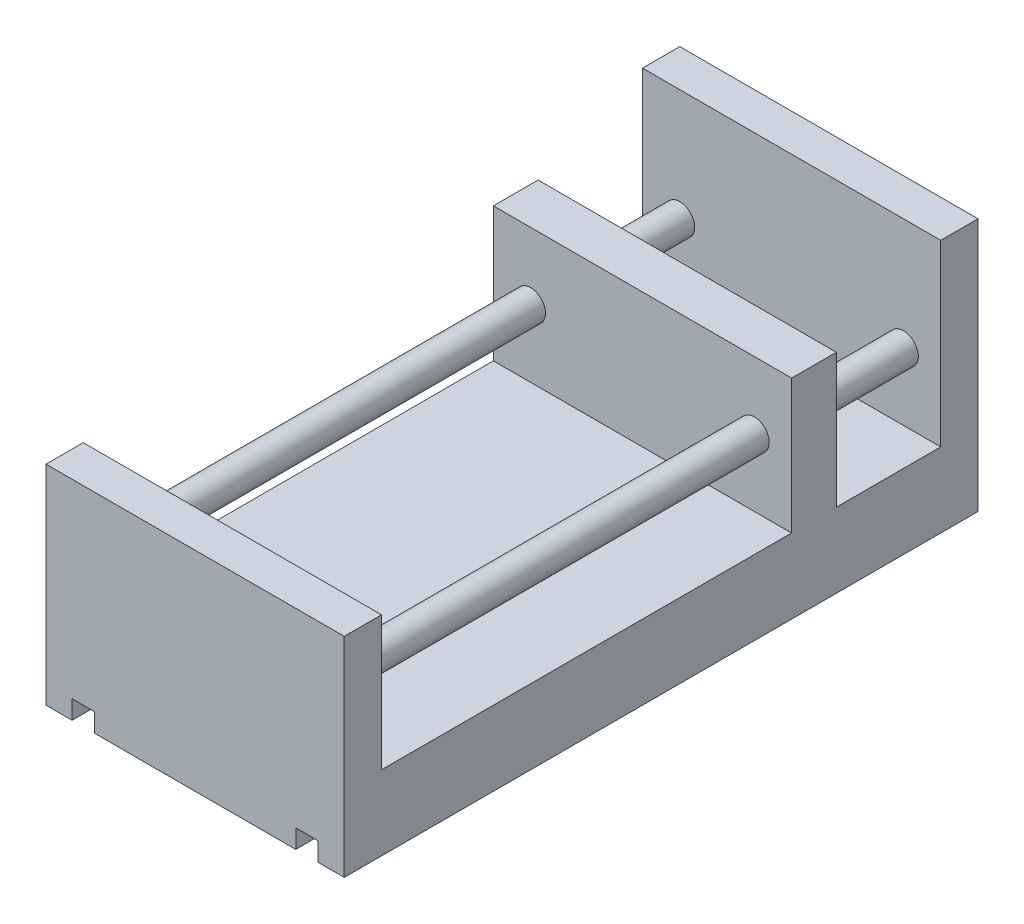
from build123d import *

# Parameters (mm, degrees)
SKETCH1_W             = 80
SKETCH1_H             = 28
BOSS_EXTRUDE1_DEPTH   = 20
SKETCH1_H_2           = 110
BOSS_EXTRUDE1_2_DEPTH = 20
SKETCH1_3_W           = 80
SKETCH1_3_H           = 12
SKETCH1_3_H_2         = 10
BOSS_EXTRUDE2_DEPTH   = 56
SKETCH1_4_W           = 80
SKETCH1_4_H           = 10
BOSS_EXTRUDE3_DEPTH   = 68
SKETCH2_R             = 4
BOSS_EXTRUDE4_DEPTH   = 150
SKETCH3_W             = 6
SKETCH3_H             = 170
CUT_EXTRUDE1_DEPTH    = 5


with BuildPart() as part:
    # Sketch1 → Boss-Extrude1 (new body)
    with BuildSketch(Plane(origin=(0, 0, 0), x_dir=(1, 0, 0), z_dir=(0, 1, 0))):
        with Locations((0, 61)):
            Rectangle(SKETCH1_W, SKETCH1_H)
    extrude(amount=BOSS_EXTRUDE1_DEPTH)



with BuildPart() as body_2:
    # Sketch1 → Boss-Extrude1 2 (new body)
    with BuildSketch(Plane(origin=(0, 0, 0), x_dir=(1, 0, 0), z_dir=(0, 1, 0))):
        with Locations((0, -20)):
            Rectangle(SKETCH1_W, SKETCH1_H_2)
    extrude(amount=BOSS_EXTRUDE1_2_DEPTH)


with BuildPart() as part_1:
    add(part.part)

    add(body_2.part)  # Boss-Extrude2 merges body 2
    # Sketch1_3 → Boss-Extrude2 (add)
    with BuildSketch(Plane(origin=(0, 0, 0), x_dir=(1, 0, 0), z_dir=(0, 1, 0))):
        with Locations((0, 41)):
            Rectangle(SKETCH1_3_W, SKETCH1_3_H)
        with Locations((0, -80)):
            Rectangle(SKETCH1_3_W, SKETCH1_3_H_2)
    extrude(amount=BOSS_EXTRUDE2_DEPTH)

    # Sketch1_4 → Boss-Extrude3 (add)
    with BuildSketch(Plane(origin=(0, 0, 0), x_dir=(1, 0, 0), z_dir=(0, 1, 0))):
        with Locations((0, 80)):
            Rectangle(SKETCH1_4_W, SKETCH1_4_H)
    extrude(amount=BOSS_EXTRUDE3_DEPTH)

    # Sketch2 → Boss-Extrude4 (add)
    with BuildSketch(Plane(origin=(0, 0, 75), x_dir=(-1, 0, 0), z_dir=(0, 0, -1))):
        with Locations((-30, 38)):
            Circle(SKETCH2_R)
        with Locations((30, 38)):
            Circle(SKETCH2_R)
    extrude(amount=BOSS_EXTRUDE4_DEPTH)

    # Sketch3 → Cut-Extrude1 (cut)
    with BuildSketch(Plane.XZ):
        with Locations((-30, 0)):
            Rectangle(SKETCH3_W, SKETCH3_H)
        with Locations((30, 0)):
            Rectangle(SKETCH3_W, SKETCH3_H)
    extrude(amount=-CUT_EXTRUDE1_DEPTH, mode=Mode.SUBTRACT)


solid = part_1.part
